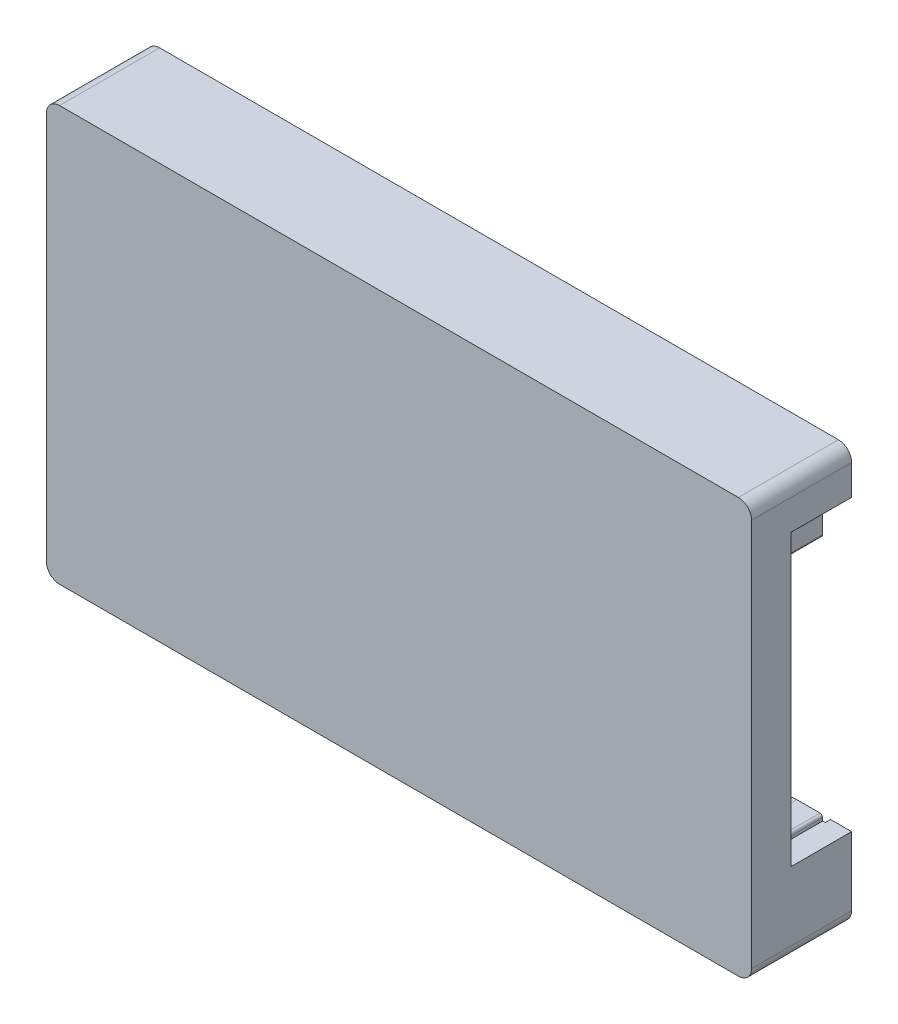
from build123d import *

# Parameters (mm, degrees)
SKETCH_1_R          = 2
SKETCH_1_R_2        = 0.7
EXTRUDE_5_DEPTH     = 3
EXTRUDE_6_DEPTH     = 7.6
SKETCH_1_8_R        = 2
SKETCH_1_8_R_2      = 0.7
EXTRUDE_7_DEPTH     = 7.2
SKETCH_1_9_W        = 1.2
SKETCH_1_9_H        = 9.6
EXTRUDE_8_DEPTH     = 3.7
FILLET_1_R          = 1
SKETCH_2_R          = 1.5
CUT_EXTRUDE_1_DEPTH = 2.4
CHAMFER_1_SIZE      = 0.8
FILLET_2_R          = 0.4
SKETCH_3_W          = 0.2
SKETCH_3_H          = 3.255284899
SKETCH_3_H_2        = 0.427
CUT_EXTRUDE_2_DEPTH = 4.2
FILLET_3_R          = 0.2


with BuildPart() as part:
    # Эскиз1 → Бобышка-Вытянуть5 (new body)
    with BuildSketch(Plane.XY):
        with BuildLine():
            Line((1.2, 20.5525), (1.2, 10.9525))
            Line((1.2, 10.9525), (1.2, 6.64))
            Line((1.2, 6.64), (5.383, 6.64))
            ThreePointArc((5.383, 6.64), (6.797213562, 6.054213562), (7.383, 4.64))
            Line((7.383, 4.64), (7.383, 1.6))
            Line((7.383, 1.6), (47.833, 1.6))
            Line((47.833, 1.6), (47.833, 4.64))
            ThreePointArc((47.833, 4.64), (48.418786438, 6.054213562), (49.833, 6.64))
            Line((49.833, 6.64), (51.984, 6.64))
            Line((51.984, 6.64), (51.984, 24.865))
            Line((51.984, 24.865), (49.833, 24.865))
            ThreePointArc((49.833, 24.865), (48.418786438, 25.450786438), (47.833, 26.865))
            Line((47.833, 26.865), (47.833, 29.905))
            Line((47.833, 29.905), (7.383, 29.905))
            Line((7.383, 29.905), (7.383, 26.865))
            ThreePointArc((7.383, 26.865), (6.797213562, 25.450786438), (5.383, 24.865))
            Line((5.383, 24.865), (1.2, 24.865))
            Line((1.2, 24.865), (1.2, 20.5525))
        make_face()
        Polygon((51.984, 6.213), (53.584, 6.213), (53.584, 28.213), (51.984, 28.213), (51.984, 24.865), (51.984, 6.64), align=None)
        with BuildLine():
            Line((51.984, 24.865), (51.984, 28.213))
            Line((51.984, 28.213), (51.984, 29.905))
            Line((51.984, 29.905), (47.833, 29.905))
            Line((47.833, 29.905), (47.833, 26.865))
            ThreePointArc((47.833, 26.865), (49.833, 28.865), (51.833, 26.865))
            ThreePointArc((51.833, 26.865), (51.247213562, 25.450786438), (49.833, 24.865))
            Line((49.833, 24.865), (51.984, 24.865))
        make_face()
        with Locations((49.833, 26.865)):
            Circle(SKETCH_1_R)
        with Locations((49.833, 26.865)):
            Circle(SKETCH_1_R_2, mode=Mode.SUBTRACT)
        with Locations((49.833, 26.865)):
            Circle(SKETCH_1_R_2)
        with BuildLine():
            Line((1.2, 29.905), (1.2, 24.865))
            Line((1.2, 24.865), (5.383, 24.865))
            ThreePointArc((5.383, 24.865), (3.968786438, 28.279213562), (7.383, 26.865))
            Line((7.383, 26.865), (7.383, 29.905))
            Line((7.383, 29.905), (1.2, 29.905))
        make_face()
        with Locations((5.383, 26.865)):
            Circle(SKETCH_1_R)
        with Locations((5.383, 26.865)):
            Circle(SKETCH_1_R_2, mode=Mode.SUBTRACT)
        with Locations((5.383, 26.865)):
            Circle(SKETCH_1_R_2)
        with BuildLine():
            Line((5.383, 6.64), (1.2, 6.64))
            Line((1.2, 6.64), (1.2, 1.6))
            Line((1.2, 1.6), (7.383, 1.6))
            Line((7.383, 1.6), (7.383, 4.64))
            ThreePointArc((7.383, 4.64), (3.968786438, 3.225786438), (5.383, 6.64))
        make_face()
        with Locations((5.383, 4.64)):
            Circle(SKETCH_1_R)
        with Locations((5.383, 4.64)):
            Circle(SKETCH_1_R_2, mode=Mode.SUBTRACT)
        with Locations((5.383, 4.64)):
            Circle(SKETCH_1_R_2)
        with BuildLine():
            Line((51.984, 1.6), (51.984, 6.213))
            Line((51.984, 6.213), (51.984, 6.64))
            Line((51.984, 6.64), (49.833, 6.64))
            ThreePointArc((49.833, 6.64), (51.247213562, 6.054213562), (51.833, 4.64))
            ThreePointArc((51.833, 4.64), (49.833, 2.64), (47.833, 4.64))
            Line((47.833, 4.64), (47.833, 1.6))
            Line((47.833, 1.6), (51.984, 1.6))
        make_face()
        with Locations((49.833, 4.64)):
            Circle(SKETCH_1_R)
        with Locations((49.833, 4.64)):
            Circle(SKETCH_1_R_2, mode=Mode.SUBTRACT)
        with Locations((49.833, 4.64)):
            Circle(SKETCH_1_R_2)
    extrude(amount=-EXTRUDE_5_DEPTH)

    # Эскиз1<7> → Бобышка-Вытянуть6 (add)
    with BuildSketch(Plane.XY):
        Polygon((0, 31.505), (0, 20.5525), (1.2, 20.5525), (1.2, 24.865), (1.2, 29.905), (7.383, 29.905), (47.833, 29.905), (51.984, 29.905), (51.984, 28.213), (53.584, 28.213), (53.584, 31.505), align=None)
        Polygon((0, 10.9525), (0, 0), (53.584, 0), (53.584, 6.213), (51.984, 6.213), (51.984, 1.6), (47.833, 1.6), (7.383, 1.6), (1.2, 1.6), (1.2, 6.64), (1.2, 10.9525), align=None)
    extrude(amount=-EXTRUDE_6_DEPTH)

    # Эскиз1<8> → Бобышка-Вытянуть7 (add)
    with BuildSketch(Plane.XY):
        with BuildLine():
            Line((51.984, 24.865), (51.984, 28.213))
            Line((51.984, 28.213), (51.984, 29.905))
            Line((51.984, 29.905), (47.833, 29.905))
            Line((47.833, 29.905), (47.833, 26.865))
            ThreePointArc((47.833, 26.865), (49.833, 28.865), (51.833, 26.865))
            ThreePointArc((51.833, 26.865), (51.247213562, 25.450786438), (49.833, 24.865))
            Line((49.833, 24.865), (51.984, 24.865))
        make_face()
        with Locations((49.833, 26.865)):
            Circle(SKETCH_1_8_R)
        with Locations((49.833, 26.865)):
            Circle(SKETCH_1_8_R_2, mode=Mode.SUBTRACT)
        with BuildLine():
            Line((1.2, 29.905), (1.2, 24.865))
            Line((1.2, 24.865), (5.383, 24.865))
            ThreePointArc((5.383, 24.865), (3.968786438, 28.279213562), (7.383, 26.865))
            Line((7.383, 26.865), (7.383, 29.905))
            Line((7.383, 29.905), (1.2, 29.905))
        make_face()
        with Locations((5.383, 26.865)):
            Circle(SKETCH_1_8_R)
        with Locations((5.383, 26.865)):
            Circle(SKETCH_1_8_R_2, mode=Mode.SUBTRACT)
        with BuildLine():
            Line((51.984, 1.6), (51.984, 6.213))
            Line((51.984, 6.213), (51.984, 6.64))
            Line((51.984, 6.64), (49.833, 6.64))
            ThreePointArc((49.833, 6.64), (51.247213562, 6.054213562), (51.833, 4.64))
            ThreePointArc((51.833, 4.64), (49.833, 2.64), (47.833, 4.64))
            Line((47.833, 4.64), (47.833, 1.6))
            Line((47.833, 1.6), (51.984, 1.6))
        make_face()
        with Locations((49.833, 4.64)):
            Circle(SKETCH_1_8_R)
        with Locations((49.833, 4.64)):
            Circle(SKETCH_1_8_R_2, mode=Mode.SUBTRACT)
        with BuildLine():
            Line((5.383, 6.64), (1.2, 6.64))
            Line((1.2, 6.64), (1.2, 1.6))
            Line((1.2, 1.6), (7.383, 1.6))
            Line((7.383, 1.6), (7.383, 4.64))
            ThreePointArc((7.383, 4.64), (3.968786438, 3.225786438), (5.383, 6.64))
        make_face()
        with Locations((5.383, 4.64)):
            Circle(SKETCH_1_8_R)
        with Locations((5.383, 4.64)):
            Circle(SKETCH_1_8_R_2, mode=Mode.SUBTRACT)
    extrude(amount=-EXTRUDE_7_DEPTH)

    # Эскиз1<9> → Бобышка-Вытянуть8 (add)
    with BuildSketch(Plane.XY):
        with Locations((0.6, 15.7525)):
            Rectangle(SKETCH_1_9_W, SKETCH_1_9_H)
    extrude(amount=-EXTRUDE_8_DEPTH)

    # Скругление1
    fillet_1_edges = [part.edges().sort_by_distance(p)[0] for p in [
        (0, 31.505, -3.8),
        (53.584, 31.505, -3.8),
        (53.584, 0, -3.8),
        (0, 0, -3.8),
    ]]
    fillet(fillet_1_edges, radius=FILLET_1_R)

    # Эскиз2 → Вырез-Вытянуть1 (cut)
    with BuildSketch(Plane(origin=(0, 0, -3), x_dir=(-1, 0, 0), z_dir=(0, 0, -1))):
        with Locations((-12.876, 4.513)):
            Circle(SKETCH_2_R)
        with BuildLine():
            Line((-44.808, 28.365), (-35.808, 28.365))
            ThreePointArc((-35.808, 28.365), (-34.308, 26.865), (-35.808, 25.365))
            Line((-35.808, 25.365), (-44.808, 25.365))
            ThreePointArc((-44.808, 25.365), (-46.308, 26.865), (-44.808, 28.365))
        make_face()
        with BuildLine():
            Line((-30.33, 28.365), (-21.33, 28.365))
            ThreePointArc((-21.33, 28.365), (-19.83, 26.865), (-21.33, 25.365))
            Line((-21.33, 25.365), (-30.33, 25.365))
            ThreePointArc((-30.33, 25.365), (-31.83, 26.865), (-30.33, 28.365))
        make_face()
    extrude(amount=-CUT_EXTRUDE_1_DEPTH, mode=Mode.SUBTRACT)

    # Фаска1
    chamfer_1_edges = [part.edges().sort_by_distance(p)[0] for p in [
        (46.308, 26.865, -3),
        (40.308, 25.365, -3),
        (34.308, 26.865, -3),
        (40.308, 28.365, -3),
        (31.83, 26.865, -3),
        (25.83, 25.365, -3),
        (19.83, 26.865, -3),
        (25.83, 28.365, -3),
        (14.376, 4.513, -3),
    ]]
    chamfer(chamfer_1_edges, length=CHAMFER_1_SIZE)

    # Скругление2
    fillet_2_edges = [part.edges().sort_by_distance(p)[0] for p in [
        (0.6, 20.5525, -3.7),
        (0.6, 10.9525, -3.7),
    ]]
    fillet(fillet_2_edges, radius=FILLET_2_R)

    # Эскиз3 → Вырез-Вытянуть2 (cut)
    with BuildSketch(Plane(origin=(0, 0, -7.2), x_dir=(-1, 0, 0), z_dir=(0, 0, -1))):
        with Locations((-51.884, 26.49264245)):
            Rectangle(SKETCH_3_W, SKETCH_3_H)
        with Locations((-51.884, 6.4265)):
            Rectangle(SKETCH_3_W, SKETCH_3_H_2)
    extrude(amount=-CUT_EXTRUDE_2_DEPTH, mode=Mode.SUBTRACT)

    # Скругление3
    fillet_3_edges = [part.edges().sort_by_distance(p)[0] for p in [
        (51.784, 24.865, -5.1),
        (51.784, 6.64, -5.1),
    ]]
    fillet(fillet_3_edges, radius=FILLET_3_R)


solid = part.part
